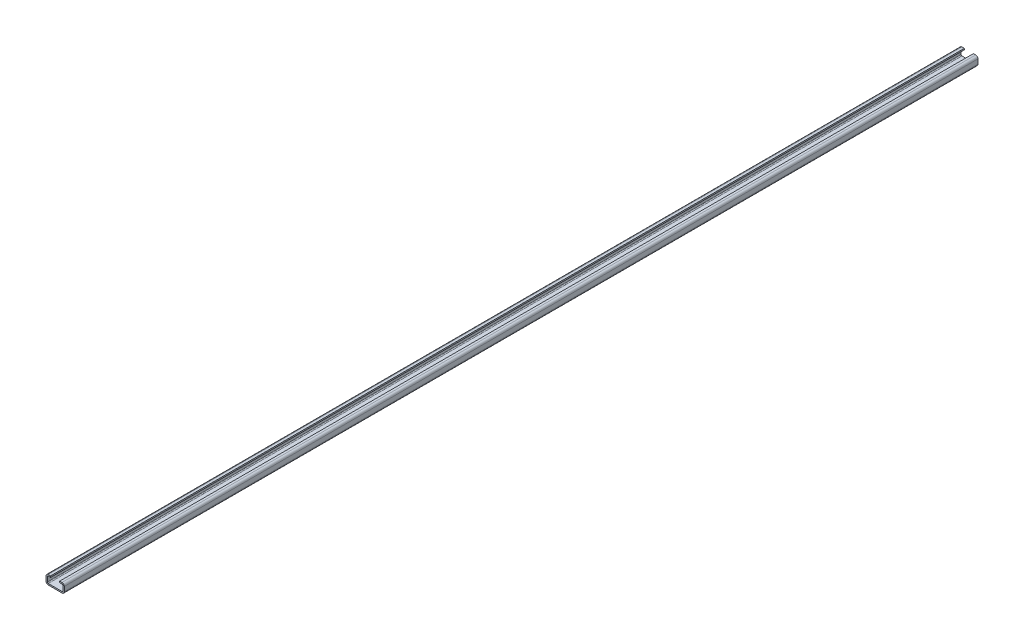
from build123d import *

# Parameters (mm, degrees)
BASE_EXTRUDE_THIN_DEPTH = 2000


with BuildPart() as part:
    # Sketch1 → Base-Extrude-Thin (new body)
    with BuildSketch(Plane.XY):
        with BuildLine():
            Line((10, 20), (15, 20))
            ThreePointArc((15, 20), (18.535533906, 18.535533906), (20, 15))
            Line((20, 15), (20, 5))
            ThreePointArc((20, 5), (18.535533906, 1.464466094), (15, 0))
            Line((15, 0), (-15, 0))
            ThreePointArc((-15, 0), (-18.535533906, 1.464466094), (-20, 5))
            Line((-20, 5), (-20, 15))
            ThreePointArc((-20, 15), (-18.535533906, 18.535533906), (-15, 20))
            Line((-15, 20), (-10, 20))
            Line((-10, 20), (-10, 17))
            Line((-10, 17), (-15, 17))
            ThreePointArc((-15, 17), (-16.414213562, 16.414213562), (-17, 15))
            Line((-17, 15), (-17, 5))
            ThreePointArc((-17, 5), (-16.414213562, 3.585786438), (-15, 3))
            Line((-15, 3), (15, 3))
            ThreePointArc((15, 3), (16.414213562, 3.585786438), (17, 5))
            Line((17, 5), (17, 15))
            ThreePointArc((17, 15), (16.414213562, 16.414213562), (15, 17))
            Line((15, 17), (10, 17))
            Line((10, 17), (10, 20))
        make_face()
    extrude(amount=BASE_EXTRUDE_THIN_DEPTH)


solid = part.part
